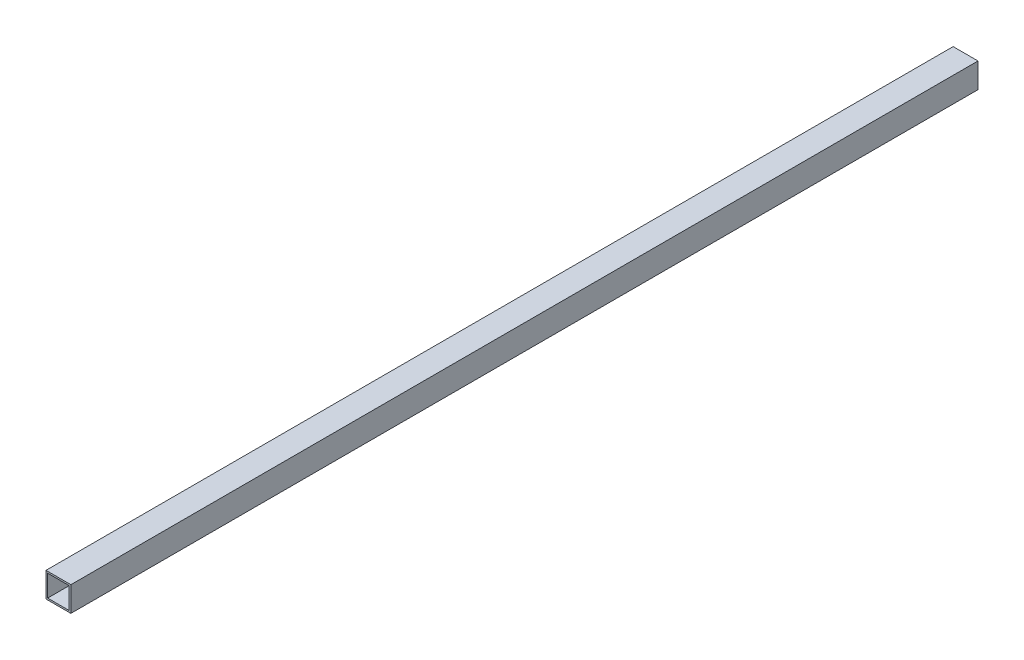
from build123d import *

# Parameters (mm, degrees)
SKETCH1_W   = 60
SKETCH1_H   = 60
SKETCH1_W_2 = 52
SKETCH1_H_2 = 52


with BuildPart() as part:
    # Sweep1: sweep along a curve in space
    with BuildLine() as sweep1_path:
        add(Edge.make_bspline(
            [(0, 0, 0), (0, 0, 2188)],
            knots=[0, 0, 1, 1], degree=1))
    # Sketch1 → Sweep1 (sweep)
    with BuildSketch(Plane.XY):
        Rectangle(SKETCH1_W, SKETCH1_H)
        Rectangle(SKETCH1_W_2, SKETCH1_H_2, mode=Mode.SUBTRACT)
    sweep(path=sweep1_path.line)


solid = part.part
